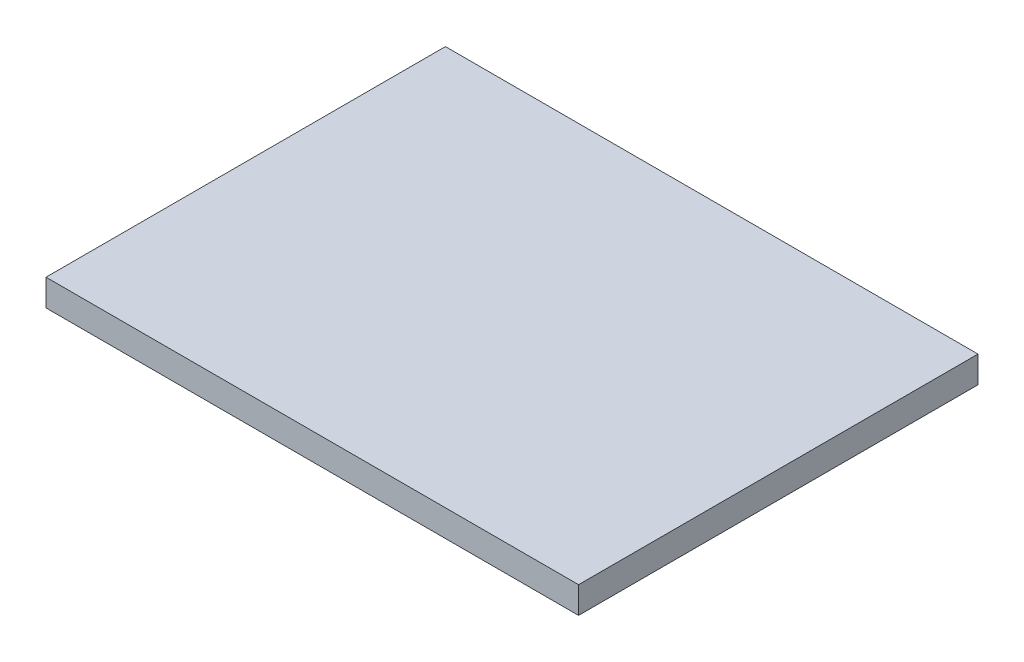
from build123d import *

# Parameters (mm, degrees)
SKETCH1_W           = 50.8
SKETCH1_H           = 38.1
BOSS_EXTRUDE1_DEPTH = 2.54


with BuildPart() as part:
    # Sketch1 → Boss-Extrude1 (new body)
    with BuildSketch(Plane(origin=(0, 0, 0), x_dir=(1, 0, 0), z_dir=(0, 1, 0))):
        with Locations((-32.209185194, 28.043639502)):
            Rectangle(SKETCH1_W, SKETCH1_H)
    extrude(amount=BOSS_EXTRUDE1_DEPTH)


solid = part.part
